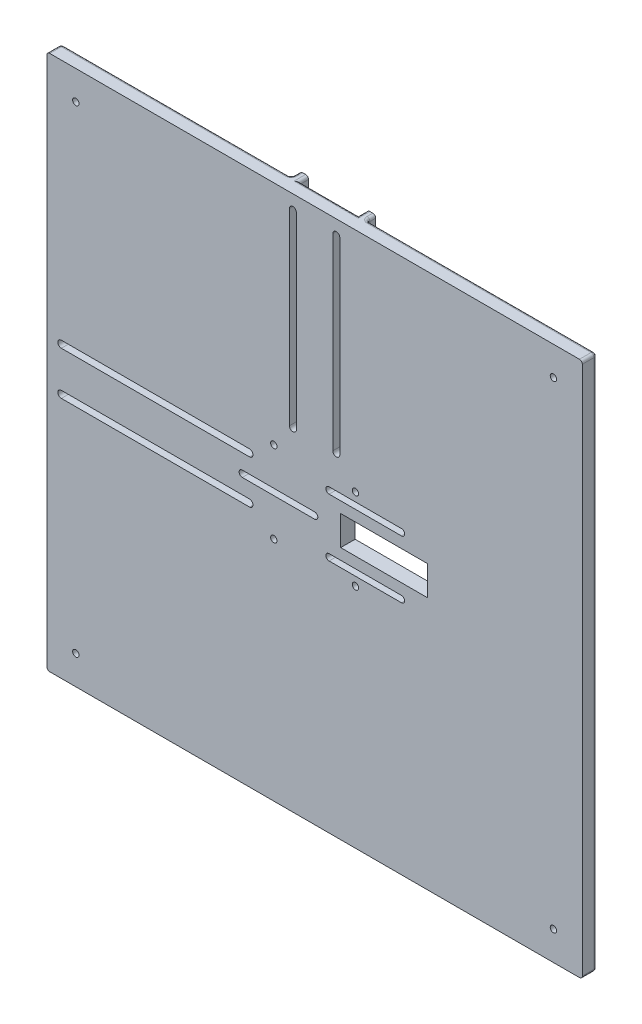
from build123d import *

# Parameters (mm, degrees)
ESQUISSE1_W              = 185
ESQUISSE1_H              = 185
BOSS_EXTRU_1_DEPTH       = 5
ESQUISSE2_W              = 70
ESQUISSE2_H              = 3
ESQUISSE2_W_2            = 3
ESQUISSE2_H_2            = 70
BOSS_EXTRU_2_DEPTH       = 3
CONG_1_R                 = 1
ENL_V_MAT_EXTRU_1_REACH  = 7
ESQUISSE4_R              = 1.1
ENL_V_MAT_EXTRU_2_DEPTH  = 6
ENL_V_MAT_EXTRU_3_REACH  = 7
ENL_V_MAT_EXTRU_5_REACH  = 10
ENL_V_MAT_EXTRU_7_REACH  = 7
ESQUISSE11_W             = 30
ESQUISSE11_H             = 10.2
ESQUISSE12_W             = 31
ESQUISSE12_H             = 4.3
ENL_V_MAT_EXTRU_9_DEPTH  = 2
CONG_2_R                 = 0.5
ENL_V_MAT_EXTRU_10_DEPTH = 2


with BuildPart() as part:
    # Esquisse1 → Boss.-Extru.1 (new body)
    with BuildSketch(Plane.XY):
        Rectangle(ESQUISSE1_W, ESQUISSE1_H)
    extrude(amount=BOSS_EXTRU_1_DEPTH)

    # Esquisse2 → Boss.-Extru.2 (add)
    with BuildSketch(Plane(origin=(0, 0, 0), x_dir=(-1, 0, 0), z_dir=(0, 0, -1))):
        with Locations((57.5, 11.6)):
            Rectangle(ESQUISSE2_W, ESQUISSE2_H)
        with Locations((57.5, -11.6)):
            Rectangle(ESQUISSE2_W, ESQUISSE2_H)
        with Locations((11.6, 57.5)):
            Rectangle(ESQUISSE2_W_2, ESQUISSE2_H_2)
        with Locations((-11.6, 57.5)):
            Rectangle(ESQUISSE2_W_2, ESQUISSE2_H_2)
    extrude(amount=BOSS_EXTRU_2_DEPTH)

    # Congé1
    cong_1_edges = [part.edges().sort_by_distance(p)[0] for p in [
        (0, 92.5, 0),
        (11.6, 22.5, 0),
        (13.1, 22.5, -1.5),
        (10.1, 92.5, -1.5),
        (13.1, 57.5, 0),
        (13.1, 92.5, -1.5),
        (-92.5, 0, 0),
        (-57.5, 13.1, 0),
        (-92.5, 13.1, -1.5),
        (-22.5, 11.6, 0),
        (-22.5, 13.1, -1.5),
        (-92.5, 10.1, -1.5),
        (-92.5, -52.8, 0),
        (-92.5, -13.1, -1.5),
        (-92.5, -10.1, -1.5),
        (-22.5, -11.6, 0),
        (-57.5, -13.1, 0),
        (-22.5, -13.1, -1.5),
        (-52.8, 92.5, 0),
        (-11.6, 22.5, 0),
        (-13.1, 57.5, 0),
        (-13.1, 22.5, -1.5),
        (-13.1, 92.5, -1.5),
        (-10.1, 92.5, -1.5),
        (52.8, 92.5, 0),
        (92.5, 0, 0),
        (0, -92.5, 0),
        (-92.5, 52.8, 0),
        (-92.5, 92.5, 2.5),
        (92.5, 92.5, 2.5),
        (92.5, -92.5, 2.5),
        (-92.5, -92.5, 2.5),
    ]]
    fillet(cong_1_edges, radius=CONG_1_R)

    # Esquisse4 → Enlèv. mat.-Extru.1 (cut, up to next)
    with BuildSketch(Plane(origin=(0, 0, 0), x_dir=(-1, 0, 0), z_dir=(0, 0, -1)), mode=Mode.PRIVATE) as enl_v_mat_extru_1_sk1:
        with Locations((-14.1, 14.1)):
            Circle(ESQUISSE4_R)
    enl_v_mat_extru_1_tool1 = extrude(enl_v_mat_extru_1_sk1.sketch, amount=-ENL_V_MAT_EXTRU_1_REACH, mode=Mode.PRIVATE) & part.part
    add(enl_v_mat_extru_1_tool1.solids().sort_by_distance((14.1, 14.1, 0))[0], mode=Mode.SUBTRACT)
    # Esquisse4 → Enlèv. mat.-Extru.1 (cut, up to next)
    with BuildSketch(Plane(origin=(0, 0, 0), x_dir=(-1, 0, 0), z_dir=(0, 0, -1)), mode=Mode.PRIVATE) as enl_v_mat_extru_1_sk2:
        with Locations((14.1, 14.1)):
            Circle(ESQUISSE4_R)
    enl_v_mat_extru_1_tool2 = extrude(enl_v_mat_extru_1_sk2.sketch, amount=-ENL_V_MAT_EXTRU_1_REACH, mode=Mode.PRIVATE) & part.part
    add(enl_v_mat_extru_1_tool2.solids().sort_by_distance((-14.1, 14.1, 0))[0], mode=Mode.SUBTRACT)
    # Esquisse4 → Enlèv. mat.-Extru.1 (cut, up to next)
    with BuildSketch(Plane(origin=(0, 0, 0), x_dir=(-1, 0, 0), z_dir=(0, 0, -1)), mode=Mode.PRIVATE) as enl_v_mat_extru_1_sk3:
        with Locations((14.1, -14.1)):
            Circle(ESQUISSE4_R)
    enl_v_mat_extru_1_tool3 = extrude(enl_v_mat_extru_1_sk3.sketch, amount=-ENL_V_MAT_EXTRU_1_REACH, mode=Mode.PRIVATE) & part.part
    add(enl_v_mat_extru_1_tool3.solids().sort_by_distance((-14.1, -14.1, 0))[0], mode=Mode.SUBTRACT)
    # Esquisse4 → Enlèv. mat.-Extru.1 (cut, up to next)
    with BuildSketch(Plane(origin=(0, 0, 0), x_dir=(-1, 0, 0), z_dir=(0, 0, -1)), mode=Mode.PRIVATE) as enl_v_mat_extru_1_sk4:
        with Locations((-14.1, -14.1)):
            Circle(ESQUISSE4_R)
    enl_v_mat_extru_1_tool4 = extrude(enl_v_mat_extru_1_sk4.sketch, amount=-ENL_V_MAT_EXTRU_1_REACH, mode=Mode.PRIVATE) & part.part
    add(enl_v_mat_extru_1_tool4.solids().sort_by_distance((14.1, -14.1, 0))[0], mode=Mode.SUBTRACT)
    # Esquisse4 → Enlèv. mat.-Extru.1 (cut, up to next)
    with BuildSketch(Plane(origin=(0, 0, 0), x_dir=(-1, 0, 0), z_dir=(0, 0, -1)), mode=Mode.PRIVATE) as enl_v_mat_extru_1_sk5:
        with Locations((-82.5, -82.5)):
            Circle(ESQUISSE4_R)
    enl_v_mat_extru_1_tool5 = extrude(enl_v_mat_extru_1_sk5.sketch, amount=-ENL_V_MAT_EXTRU_1_REACH, mode=Mode.PRIVATE) & part.part
    add(enl_v_mat_extru_1_tool5.solids().sort_by_distance((82.5, -82.5, 0))[0], mode=Mode.SUBTRACT)
    # Esquisse4 → Enlèv. mat.-Extru.1 (cut, up to next)
    with BuildSketch(Plane(origin=(0, 0, 0), x_dir=(-1, 0, 0), z_dir=(0, 0, -1)), mode=Mode.PRIVATE) as enl_v_mat_extru_1_sk6:
        with Locations((-82.5, 82.5)):
            Circle(ESQUISSE4_R)
    enl_v_mat_extru_1_tool6 = extrude(enl_v_mat_extru_1_sk6.sketch, amount=-ENL_V_MAT_EXTRU_1_REACH, mode=Mode.PRIVATE) & part.part
    add(enl_v_mat_extru_1_tool6.solids().sort_by_distance((82.5, 82.5, 0))[0], mode=Mode.SUBTRACT)
    # Esquisse4 → Enlèv. mat.-Extru.1 (cut, up to next)
    with BuildSketch(Plane(origin=(0, 0, 0), x_dir=(-1, 0, 0), z_dir=(0, 0, -1)), mode=Mode.PRIVATE) as enl_v_mat_extru_1_sk7:
        with Locations((82.5, -82.5)):
            Circle(ESQUISSE4_R)
    enl_v_mat_extru_1_tool7 = extrude(enl_v_mat_extru_1_sk7.sketch, amount=-ENL_V_MAT_EXTRU_1_REACH, mode=Mode.PRIVATE) & part.part
    add(enl_v_mat_extru_1_tool7.solids().sort_by_distance((-82.5, -82.5, 0))[0], mode=Mode.SUBTRACT)
    # Esquisse4 → Enlèv. mat.-Extru.1 (cut, up to next)
    with BuildSketch(Plane(origin=(0, 0, 0), x_dir=(-1, 0, 0), z_dir=(0, 0, -1)), mode=Mode.PRIVATE) as enl_v_mat_extru_1_sk8:
        with Locations((82.5, 82.5)):
            Circle(ESQUISSE4_R)
    enl_v_mat_extru_1_tool8 = extrude(enl_v_mat_extru_1_sk8.sketch, amount=-ENL_V_MAT_EXTRU_1_REACH, mode=Mode.PRIVATE) & part.part
    add(enl_v_mat_extru_1_tool8.solids().sort_by_distance((-82.5, 82.5, 0))[0], mode=Mode.SUBTRACT)

    # Esquisse5 → Enlèv. mat.-Extru.2 (cut, through all)
    with BuildSketch(Plane(origin=(0, 0, 0), x_dir=(-1, 0, 0), z_dir=(0, 0, -1))):
        with BuildLine():
            Line((-6.3, 87.5), (-6.3, 22.5))
            ThreePointArc((-6.3, 22.5), (-7.5, 21.3), (-8.7, 22.5))
            Line((-8.7, 22.5), (-8.7, 87.5))
            ThreePointArc((-8.7, 87.5), (-7.5, 88.7), (-6.3, 87.5))
        make_face()
        with BuildLine():
            Line((8.7, 87.5), (8.7, 22.5))
            ThreePointArc((8.7, 22.5), (7.5, 21.3), (6.3, 22.5))
            Line((6.3, 22.5), (6.3, 87.5))
            ThreePointArc((6.3, 87.5), (7.5, 88.7), (8.7, 87.5))
        make_face()
    extrude(amount=-ENL_V_MAT_EXTRU_2_DEPTH, mode=Mode.SUBTRACT)

    # Esquisse6 → Enlèv. mat.-Extru.3 (cut, up to next)
    with BuildSketch(Plane(origin=(0, 0, 0), x_dir=(-1, 0, 0), z_dir=(0, 0, -1)), mode=Mode.PRIVATE) as enl_v_mat_extru_3_sk1:
        with BuildLine():
            Line((87.5, -8.7), (22.5, -8.7))
            ThreePointArc((22.5, -8.7), (21.3, -7.5), (22.5, -6.3))
            Line((22.5, -6.3), (87.5, -6.3))
            ThreePointArc((87.5, -6.3), (88.7, -7.5), (87.5, -8.7))
        make_face()
    enl_v_mat_extru_3_tool1 = extrude(enl_v_mat_extru_3_sk1.sketch, amount=-ENL_V_MAT_EXTRU_3_REACH, mode=Mode.PRIVATE) & part.part
    add(enl_v_mat_extru_3_tool1.solids().sort_by_distance((-55, -7.5, 0))[0], mode=Mode.SUBTRACT)
    # Esquisse6 → Enlèv. mat.-Extru.3 (cut, up to next)
    with BuildSketch(Plane(origin=(0, 0, 0), x_dir=(-1, 0, 0), z_dir=(0, 0, -1)), mode=Mode.PRIVATE) as enl_v_mat_extru_3_sk2:
        with BuildLine():
            Line((22.5, 8.7), (87.5, 8.7))
            ThreePointArc((87.5, 8.7), (88.7, 7.5), (87.5, 6.3))
            Line((87.5, 6.3), (22.5, 6.3))
            ThreePointArc((22.5, 6.3), (21.3, 7.5), (22.5, 8.7))
        make_face()
    enl_v_mat_extru_3_tool2 = extrude(enl_v_mat_extru_3_sk2.sketch, amount=-ENL_V_MAT_EXTRU_3_REACH, mode=Mode.PRIVATE) & part.part
    add(enl_v_mat_extru_3_tool2.solids().sort_by_distance((-55, 7.5, 0))[0], mode=Mode.SUBTRACT)

    # Esquisse9 → Enlèv. mat.-Extru.5 (cut, up to next)
    with BuildSketch(Plane.XY.offset(5), mode=Mode.PRIVATE) as enl_v_mat_extru_5_sk1:
        with BuildLine():
            Line((-25, 1.1), (0, 1.1))
            ThreePointArc((0, 1.1), (1.1, 0), (0, -1.1))
            Line((0, -1.1), (-25, -1.1))
            ThreePointArc((-25, -1.1), (-26.1, 0), (-25, 1.1))
        make_face()
    enl_v_mat_extru_5_tool1 = extrude(enl_v_mat_extru_5_sk1.sketch, amount=-ENL_V_MAT_EXTRU_5_REACH, mode=Mode.PRIVATE) & part.part
    add(enl_v_mat_extru_5_tool1.solids().sort_by_distance((-12.5, 0, 5))[0], mode=Mode.SUBTRACT)
    # Esquisse9 → Enlèv. mat.-Extru.5 (cut, up to next)
    with BuildSketch(Plane.XY.offset(5), mode=Mode.PRIVATE) as enl_v_mat_extru_5_sk2:
        with BuildLine():
            Line((5, 11.1), (30, 11.1))
            ThreePointArc((30, 11.1), (31.1, 10), (30, 8.9))
            Line((30, 8.9), (5, 8.9))
            ThreePointArc((5, 8.9), (3.9, 10), (5, 11.1))
        make_face()
    enl_v_mat_extru_5_tool2 = extrude(enl_v_mat_extru_5_sk2.sketch, amount=-ENL_V_MAT_EXTRU_5_REACH, mode=Mode.PRIVATE) & part.part
    add(enl_v_mat_extru_5_tool2.solids().sort_by_distance((17.5, 10, 5))[0], mode=Mode.SUBTRACT)
    # Esquisse9 → Enlèv. mat.-Extru.5 (cut, up to next)
    with BuildSketch(Plane.XY.offset(5), mode=Mode.PRIVATE) as enl_v_mat_extru_5_sk3:
        with BuildLine():
            Line((5, -8.9), (30, -8.9))
            ThreePointArc((30, -8.9), (31.1, -10), (30, -11.1))
            Line((30, -11.1), (5, -11.1))
            ThreePointArc((5, -11.1), (3.9, -10), (5, -8.9))
        make_face()
    enl_v_mat_extru_5_tool3 = extrude(enl_v_mat_extru_5_sk3.sketch, amount=-ENL_V_MAT_EXTRU_5_REACH, mode=Mode.PRIVATE) & part.part
    add(enl_v_mat_extru_5_tool3.solids().sort_by_distance((17.5, -10, 5))[0], mode=Mode.SUBTRACT)

    # Esquisse11 → Enlèv. mat.-Extru.7 (cut, up to next)
    with BuildSketch(Plane(origin=(0, 0, 0), x_dir=(-1, 0, 0), z_dir=(0, 0, -1)), mode=Mode.PRIVATE) as enl_v_mat_extru_7_sk1:
        with Locations((-24, 0)):
            Rectangle(ESQUISSE11_W, ESQUISSE11_H)
    enl_v_mat_extru_7_tool1 = extrude(enl_v_mat_extru_7_sk1.sketch, amount=-ENL_V_MAT_EXTRU_7_REACH, mode=Mode.PRIVATE) & part.part
    add(enl_v_mat_extru_7_tool1.solids().sort_by_distance((24, 0, 0))[0], mode=Mode.SUBTRACT)

    # Esquisse12 → Enlèv. mat.-Extru.9 (cut)
    with BuildSketch(Plane(origin=(0, 0, 0), x_dir=(-1, 0, 0), z_dir=(0, 0, -1))):
        with Locations((-17.5, 9.95)):
            Rectangle(ESQUISSE12_W, ESQUISSE12_H)
        with Locations((-17.5, -10.05)):
            Rectangle(ESQUISSE12_W, ESQUISSE12_H)
        with Locations((12.5, -0.05)):
            Rectangle(ESQUISSE12_W, ESQUISSE12_H)
    extrude(amount=-ENL_V_MAT_EXTRU_9_DEPTH, mode=Mode.SUBTRACT)

    # Congé2
    cong_2_edges = [part.edges().sort_by_distance(p)[0] for p in [
        (33, 7.8, 1),
        (33, 12.1, 1),
        (2, 12.1, 1),
        (33, -12.2, 1),
        (33, -7.9, 1),
        (2, -7.9, 1),
        (2, -12.2, 1),
        (3, -2.2, 1),
        (3, 2.1, 1),
        (-28, 2.1, 1),
        (-28, -2.2, 1),
    ]]
    fillet(cong_2_edges, radius=CONG_2_R)

    # Esquisse13 → Enlèv. mat.-Extru.10 (cut)
    with BuildSketch(Plane(origin=(0, 0, 0), x_dir=(-1, 0, 0), z_dir=(0, 0, -1))):
        Polygon((-80, -82.5), (-81.25, -80.334936491), (-83.75, -80.334936491), (-85, -82.5), (-83.75, -84.665063509), (-81.25, -84.665063509), align=None)
        Polygon((83.75, -84.665063509), (85, -82.5), (83.75, -80.334936491), (81.25, -80.334936491), (80, -82.5), (81.25, -84.665063509), align=None)
        Polygon((85, 82.5), (83.75, 84.665063509), (81.25, 84.665063509), (80, 82.5), (81.25, 80.334936491), (83.75, 80.334936491), align=None)
        Polygon((-80, 82.5), (-81.25, 84.665063509), (-83.75, 84.665063509), (-85, 82.5), (-83.75, 80.334936491), (-81.25, 80.334936491), align=None)
    extrude(amount=-ENL_V_MAT_EXTRU_10_DEPTH, mode=Mode.SUBTRACT)


solid = part.part
